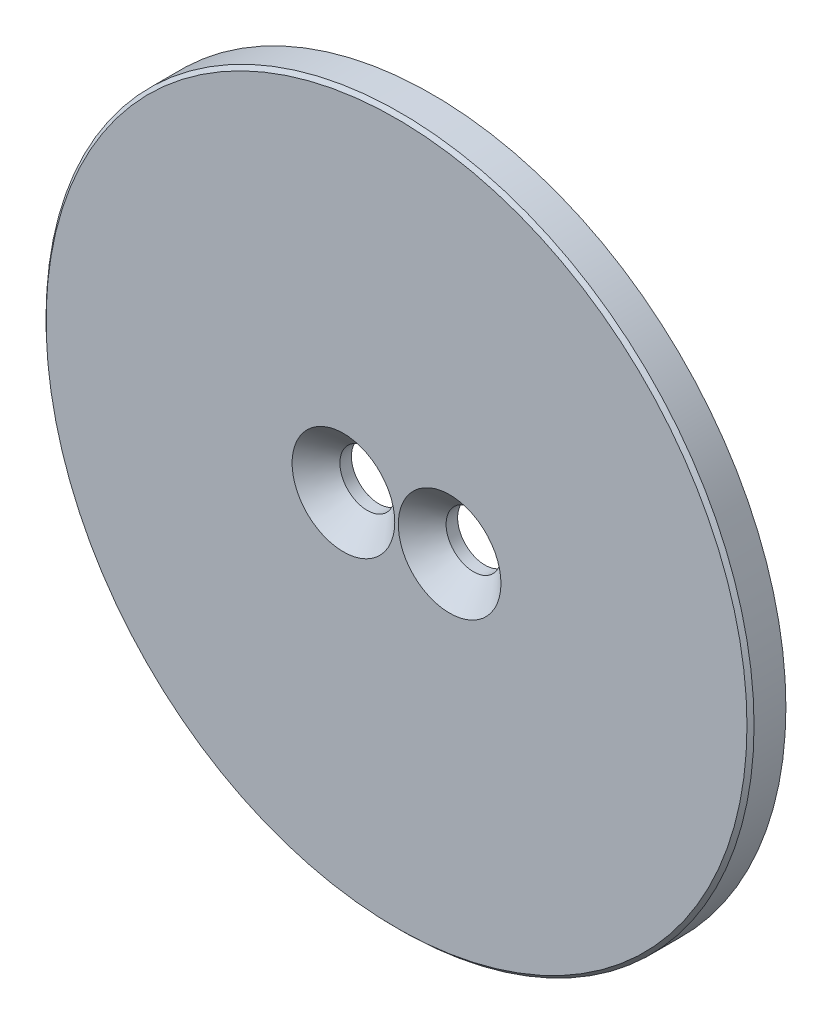
from build123d import *

# Parameters (mm, degrees)
SKETCH_1_R                   = 20
EXTRUDE_1_DEPTH              = 2
SKETCH_2_R                   = 1.55
CUT_EXTRUDE_1_DEPTH          = 2
HOLE_WIZARD_M3_1_D           = 3.1
HOLE_WIZARD_M3_1_DEPTH       = 10
HOLE_WIZARD_M3_1_CSINK_D     = 5.8
HOLE_WIZARD_M3_1_CSINK_ANGLE = 90
CHAMFER_1_SIZE               = 0.2


with BuildPart() as part:
    # 草图1 → 凸台-拉伸1 (new body)
    with BuildSketch(Plane.XY):
        Circle(SKETCH_1_R)
    extrude(amount=EXTRUDE_1_DEPTH)

    # 草图2 → 切除-拉伸1 (cut)
    with BuildSketch(Plane.XY.offset(2)):
        with Locations((-3, 0)):
            Circle(SKETCH_2_R)
        with Locations((3, 0)):
            Circle(SKETCH_2_R)
    extrude(amount=-CUT_EXTRUDE_1_DEPTH, mode=Mode.SUBTRACT)

    # M3 六角凹锥坑螺钉的锥形沉头孔1
    with Locations(Plane(origin=(-3, 0, 2), x_dir=(1, 0, 0), z_dir=(0, 0, 1))):
        with Locations((0, 0), (6, 0)):
            CounterSinkHole(HOLE_WIZARD_M3_1_D / 2, HOLE_WIZARD_M3_1_CSINK_D / 2, depth=HOLE_WIZARD_M3_1_DEPTH, counter_sink_angle=HOLE_WIZARD_M3_1_CSINK_ANGLE)

    # 倒角1
    chamfer_1_edges = [part.edges().sort_by_distance(p)[0] for p in [
        (-20, 0, 2),
    ]]
    chamfer(chamfer_1_edges, length=CHAMFER_1_SIZE)


solid = part.part
